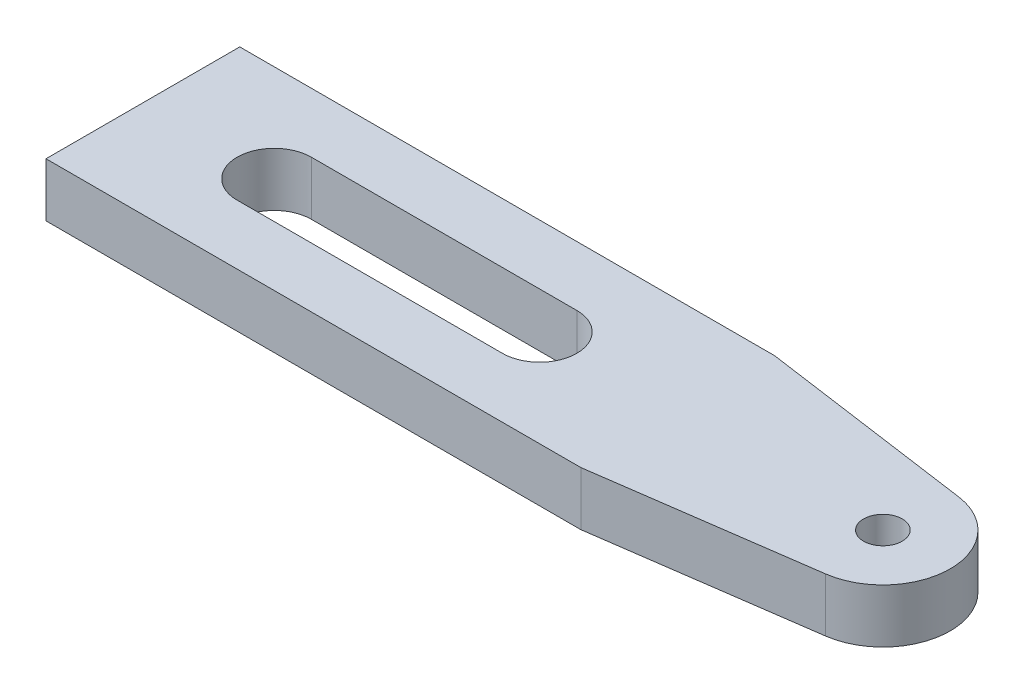
from build123d import *

# Parameters (mm, degrees)
BOSS_EXTRUDE1_DEPTH = 2.032
CUT_EXTRUDE1_REACH  = 4.032
CUT_EXTRUDE2_REACH  = 4.032
SKETCH3_R           = 0.73025


with BuildPart() as part:
    # Sketch1 → Boss-Extrude1 (new body)
    with BuildSketch(Plane(origin=(0, 0, 0), x_dir=(1, 0, 0), z_dir=(0, 1, 0))):
        with BuildLine():
            Line((-15.24, 3.6576), (-15.24, -3.6576))
            Line((-15.24, -3.6576), (4.953, -3.6576))
            Line((4.953, -3.6576), (13.054677298, -2.51511511))
            ThreePointArc((13.054677298, -2.51511511), (15.24, 0), (13.054677298, 2.51511511))
            Line((13.054677298, 2.51511511), (4.953, 3.6576))
            Line((4.953, 3.6576), (-15.24, 3.6576))
        make_face()
    extrude(amount=BOSS_EXTRUDE1_DEPTH)

    # Sketch2 → Cut-Extrude1 (cut, up to next)
    with BuildSketch(Plane(origin=(0, 2.032, 0), x_dir=(1, 0, 0), z_dir=(0, 1, 0)), mode=Mode.PRIVATE) as cut_extrude1_sk1:
        with BuildLine():
            Line((-10.28065, 1.40335), (-0.26035, 1.40335))
            ThreePointArc((-0.26035, 1.40335), (1.143, 0), (-0.26035, -1.40335))
            Line((-0.26035, -1.40335), (-10.28065, -1.40335))
            ThreePointArc((-10.28065, -1.40335), (-11.684, 0), (-10.28065, 1.40335))
        make_face()
    cut_extrude1_tool1 = extrude(cut_extrude1_sk1.sketch, amount=-CUT_EXTRUDE1_REACH, mode=Mode.PRIVATE) & part.part
    add(cut_extrude1_tool1.solids().sort_by_distance((-5.2705, 2.032, 0))[0], mode=Mode.SUBTRACT)

    # Sketch3 → Cut-Extrude2 (cut, up to next)
    with BuildSketch(Plane(origin=(0, 2.032, 0), x_dir=(1, 0, 0), z_dir=(0, 1, 0)), mode=Mode.PRIVATE) as cut_extrude2_sk1:
        with Locations((12.7, 0)):
            Circle(SKETCH3_R)
    cut_extrude2_tool1 = extrude(cut_extrude2_sk1.sketch, amount=-CUT_EXTRUDE2_REACH, mode=Mode.PRIVATE) & part.part
    add(cut_extrude2_tool1.solids().sort_by_distance((12.7, 2.032, 0))[0], mode=Mode.SUBTRACT)


solid = part.part
